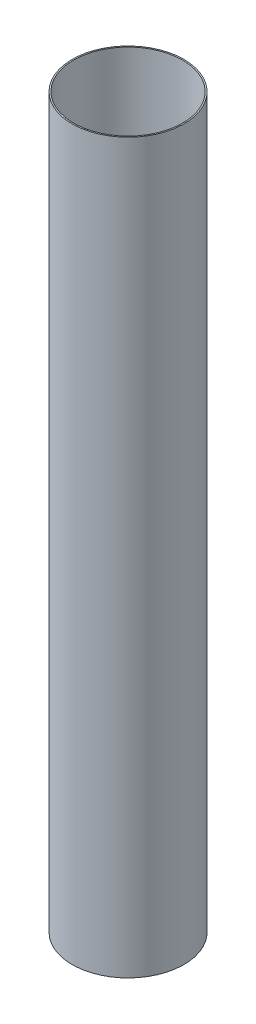
from build123d import *

# Parameters (mm, degrees)
SKETCH1_W = 0.4572
SKETCH1_H = 254


with BuildPart() as part:
    # Sketch1 → Revolve1 (revolve)
    with BuildSketch(Plane.XY):
        with Locations((19.2659, 127)):
            Rectangle(SKETCH1_W, SKETCH1_H)
    revolve(axis=Axis((0, -13.97, 0), (0, 1, 0)))


solid = part.part
